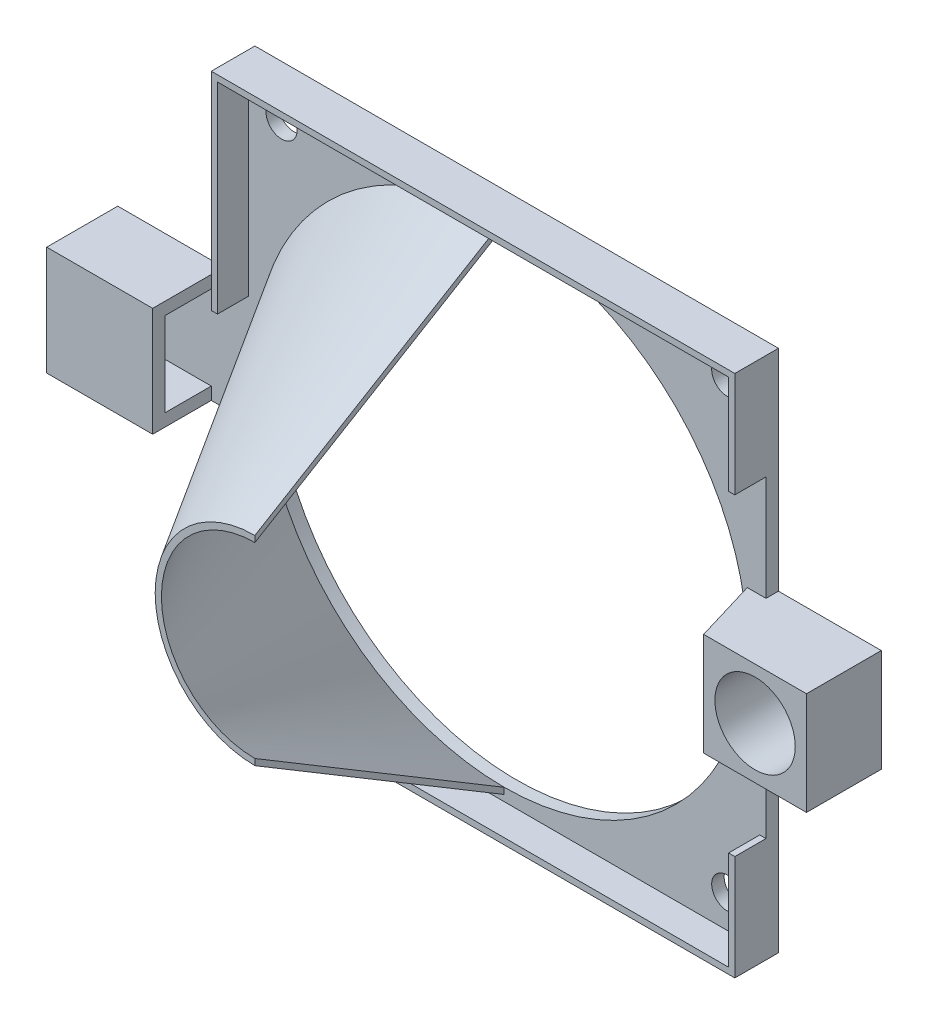
from build123d import *

# Parameters (mm, degrees)
CROQUIS1_W              = 84
CROQUIS1_H              = 84
CROQUIS1_R              = 39
CROQUIS1_R_2            = 2.5
SALIENTE_EXTRUIR1_DEPTH = 2
REVOLUCI_N2_ANGLE       = 180
SALIENTE_EXTRUIR2_DEPTH = 20
SALIENTE_EXTRUIR3_DEPTH = 15
CROQUIS8_W              = 11.4
CROQUIS8_H              = 17.5
CROQUIS8_R              = 3.6
SALIENTE_EXTRUIR4_DEPTH = 2
SALIENTE_EXTRUIR5_DEPTH = 16.5
CROQUIS10_W             = 16.5
CROQUIS10_H             = 16.5
CROQUIS10_R             = 6.45
SALIENTE_EXTRUIR6_DEPTH = 10
SALIENTE_EXTRUIR7_START = -16.5
SALIENTE_EXTRUIR7_DEPTH = 16.5
SALIENTE_EXTRUIR8_DEPTH = 5
CROQUIS13_R             = 2.5
CORTAR_EXTRUIR1_DEPTH   = 2


with BuildPart() as part:
    # Croquis1 → Saliente-Extruir1 (new body)
    with BuildSketch(Plane.XY):
        with Locations((-61.319838057, -7.506072874)):
            Rectangle(CROQUIS1_W, CROQUIS1_H)
        with Locations((-61.319838057, -7.506072874)):
            Circle(CROQUIS1_R, mode=Mode.SUBTRACT)
        with Locations((-97.028730507, 28.202819575)):
            Circle(CROQUIS1_R_2, mode=Mode.SUBTRACT)
        with Locations((-25.528730507, 28.202819575)):
            Circle(CROQUIS1_R_2, mode=Mode.SUBTRACT)
        with Locations((-25.528730507, -43.297180425)):
            Circle(CROQUIS1_R_2, mode=Mode.SUBTRACT)
        with Locations((-97.028730507, -43.297180425)):
            Circle(CROQUIS1_R_2, mode=Mode.SUBTRACT)
    extrude(amount=SALIENTE_EXTRUIR1_DEPTH)

    # Croquis4 → Revolución2 (revolve)
    with BuildSketch(Plane(origin=(-61.319838057, -49.506072874, 2), x_dir=(0, 0, -1), z_dir=(1, 0, 0))):
        Polygon((-40, 27), (0, 3), (0, 2), (-40, 26), align=None)
    revolve(axis=Axis((-61.319838057, -7.506072874, 2), (0, 0, -1)), revolution_arc=REVOLUCI_N2_ANGLE)

    # Croquis6 → Saliente-Extruir2 (add)
    with BuildSketch(Plane.ZY.offset(103.319838057)):
        Polygon((0, -7.506072874), (0, -16.256072874), (2, -16.256072874), (2, 1.243927126), (0, 1.243927126), align=None)
    extrude(amount=SALIENTE_EXTRUIR2_DEPTH)

    # Croquis7 → Saliente-Extruir3 (add)
    with BuildSketch(Plane.ZY.offset(123.319838057)):
        Polygon((11.4, 1.243927126), (2, 1.243927126), (2, -0.756072874), (9.4, -0.756072874), (9.4, -14.256072874), (2, -14.256072874), (2, -16.256072874), (11.4, -16.256072874), align=None)
    extrude(amount=-SALIENTE_EXTRUIR3_DEPTH)

    # Croquis8 → Saliente-Extruir4 (add)
    with BuildSketch(Plane.ZY.offset(123.319838057)):
        with Locations((5.7, -7.506072874)):
            Rectangle(CROQUIS8_W, CROQUIS8_H)
        with Locations((5.7, -7.506072874)):
            Circle(CROQUIS8_R, mode=Mode.SUBTRACT)
    extrude(amount=SALIENTE_EXTRUIR4_DEPTH)

    # Croquis9 → Saliente-Extruir5 (add)
    with BuildSketch(Plane(origin=(-19.319838057, 0, 0), x_dir=(0, 0, -1), z_dir=(1, 0, 0))):
        Polygon((0, -7.506072874), (0, 0.743927126), (-2, 0.743927126), (-2, -15.756072874), (0, -15.756072874), align=None)
    extrude(amount=SALIENTE_EXTRUIR5_DEPTH)

    # Croquis10 → Saliente-Extruir6 (add)
    with BuildSketch(Plane.XY.offset(2)):
        with Locations((-11.069838057, -7.506072874)):
            Rectangle(CROQUIS10_W, CROQUIS10_H)
        with Locations((-11.069838057, -7.506072874)):
            Circle(CROQUIS10_R, mode=Mode.SUBTRACT)
    extrude(amount=SALIENTE_EXTRUIR6_DEPTH)

    # Croquis11 → Saliente-Extruir7 (add)
    with BuildSketch(Plane(origin=(0, 0.743927126, 0), x_dir=(1, 0, 0), z_dir=(0, 1, 0)).offset(SALIENTE_EXTRUIR7_START)):
        Polygon((-19.319838057, -12), (-19.319838057, -2), (-22.319838057, -2), align=None)
    extrude(amount=SALIENTE_EXTRUIR7_DEPTH)

    # Croquis12 → Saliente-Extruir8 (add)
    with BuildSketch(Plane.XY.offset(2)):
        Polygon((-19.319838057, -32.631072874), (-20.319838057, -32.631072874), (-20.319838057, -48.506072874), (-102.319838057, -48.506072874), (-102.319838057, -16.256072874), (-103.319838057, -16.256072874), (-103.319838057, -49.506072874), (-19.319838057, -49.506072874), align=None)
        Polygon((-19.319838057, 34.493927126), (-103.319838057, 34.493927126), (-103.319838057, 1.243927126), (-102.319838057, 1.243927126), (-102.319838057, 33.493927126), (-20.319838057, 33.493927126), (-20.319838057, 17.618927126), (-19.319838057, 17.618927126), align=None)
    extrude(amount=SALIENTE_EXTRUIR8_DEPTH)

    # Croquis13 → Cortar-Extruir1 (cut)
    with BuildSketch(Plane.XY.offset(2)):
        with Locations((-11.069838057, -7.506072874)):
            Circle(CROQUIS13_R)
    extrude(amount=-CORTAR_EXTRUIR1_DEPTH, mode=Mode.SUBTRACT)


solid = part.part
